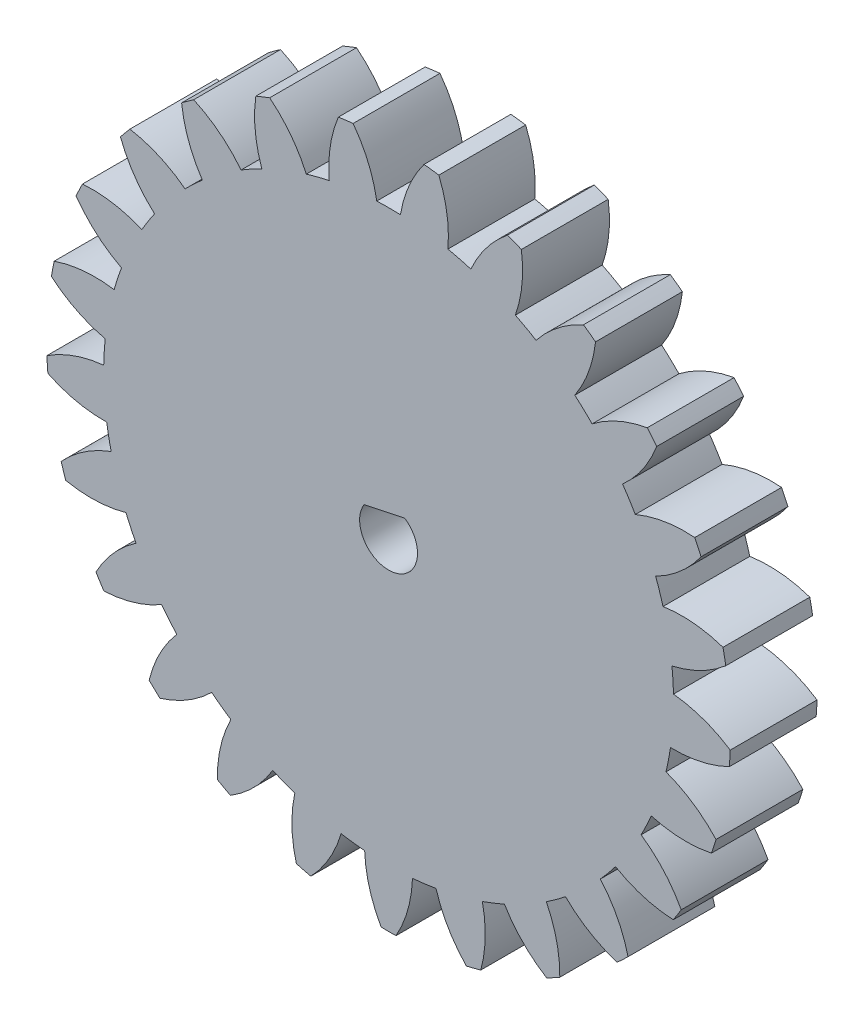
from build123d import *

# Parameters (mm, degrees)
BOSS_EXTRUDE1_DEPTH = 6
CUT_EXTRUDE1_DEPTH  = 6


with BuildPart() as part:
    # Sketch1 → Boss-Extrude1 (new body)
    with BuildSketch(Plane.XY):
        with BuildLine():
            ThreePointArc((-23.297478626, 3.98388923), (-21.550990273, 2.825758414), (-19.579218077, 2.11610853))
            ThreePointArc((-19.579218077, 2.11610853), (-19.647653189, 1.299796091), (-19.682068786, 0.481343326))
            ThreePointArc((-19.682068786, 0.481343326), (-21.727235684, 0.024417829), (-23.605104735, -0.905687747))
            ThreePointArc((-23.605104735, -0.905687747), (-23.578381459, -1.419755495), (-23.540464241, -1.93311898))
            ThreePointArc((-23.540464241, -1.93311898), (-21.560829609, -2.620530995), (-19.474521512, -2.817526118))
            ThreePointArc((-19.474521512, -2.817526118), (-19.337797961, -3.625211721), (-19.167591403, -4.426510099))
            ThreePointArc((-19.167591403, -4.426510099), (-21.034872872, -5.377692766), (-22.622437362, -6.745584408))
            ThreePointArc((-22.622437362, -6.745584408), (-22.468710197, -7.236855963), (-22.304315911, -7.724661561))
            ThreePointArc((-22.304315911, -7.724661561), (-20.215922725, -7.898162151), (-18.146169139, -7.570124585))
            ThreePointArc((-18.146169139, -7.570124585), (-17.812877768, -8.318433495), (-17.448743759, -9.052228961))
            ThreePointArc((-17.448743759, -9.052228961), (-19.020811637, -10.437902494), (-20.218319051, -12.157630537))
            ThreePointArc((-20.218319051, -12.157630537), (-19.94724724, -12.595237503), (-19.666705383, -13.026834594))
            ThreePointArc((-19.666705383, -13.026834594), (-17.600775067, -12.675522078), (-15.677626222, -11.843063629))
            ThreePointArc((-15.677626222, -11.843063629), (-15.168708954, -12.484976846), (-14.633527372, -13.105162332))
            ThreePointArc((-14.633527372, -13.105162332), (-15.811602852, -14.838259766), (-16.543809396, -16.801767375))
            ThreePointArc((-16.543809396, -16.801767375), (-16.172425378, -17.158213294), (-15.793363427, -17.506483047))
            ThreePointArc((-15.793363427, -17.506483047), (-13.879705981, -16.652431682), (-12.22400039, -15.367858777))
            ThreePointArc((-12.22400039, -15.367858777), (-11.571434369, -15.863042531), (-10.898832642, -16.330649503))
            ThreePointArc((-10.898832642, -16.330649503), (-11.60889291, -18.302273952), (-11.829791353, -20.386186721))
            ThreePointArc((-11.829791353, -20.386186721), (-11.381430551, -20.639074787), (-10.927666363, -20.882134132))
            ThreePointArc((-10.927666363, -20.882134132), (-9.286523922, -19.579007107), (-8.002295658, -17.923034185))
            ThreePointArc((-8.002295658, -17.923034185), (-7.247084006, -18.240374261), (-6.479324175, -18.526021252))
            ThreePointArc((-6.479324175, -18.526021252), (-6.676753531, -20.612288301), (-6.372464012, -22.685666328))
            ThreePointArc((-6.372464012, -22.685666328), (-5.875298584, -22.819106653), (-5.375343832, -22.941683276))
            ThreePointArc((-5.375343832, -22.941683276), (-4.109835412, -21.271360855), (-3.277777259, -19.348038785))
            ThreePointArc((-3.277777259, -19.348038785), (-2.467372703, -19.467595539), (-1.65269594, -19.553334298))
            ThreePointArc((-1.65269594, -19.553334298), (-1.325089173, -21.623156117), (-0.514731321, -23.555721434))
            ThreePointArc((-0.514731321, -23.555721434), (0, -23.561329471), (0.514731321, -23.555721434))
            ThreePointArc((0.514731321, -23.555721434), (1.325089173, -21.623156117), (1.65269594, -19.553334298))
            ThreePointArc((1.65269594, -19.553334298), (2.467372703, -19.467595539), (3.277777259, -19.348038785))
            ThreePointArc((3.277777259, -19.348038785), (4.109835412, -21.271360855), (5.375343832, -22.941683276))
            ThreePointArc((5.375343832, -22.941683276), (5.875298584, -22.819106653), (6.372464012, -22.685666328))
            ThreePointArc((6.372464012, -22.685666328), (6.676753531, -20.612288301), (6.479324175, -18.526021252))
            ThreePointArc((6.479324175, -18.526021252), (7.247084006, -18.240374261), (8.002295658, -17.923034185))
            ThreePointArc((8.002295658, -17.923034185), (9.286523922, -19.579007107), (10.927666363, -20.882134132))
            ThreePointArc((10.927666363, -20.882134132), (11.381430551, -20.639074787), (11.829791353, -20.386186721))
            ThreePointArc((11.829791353, -20.386186721), (11.60889291, -18.302273952), (10.898832642, -16.330649503))
            ThreePointArc((10.898832642, -16.330649503), (11.571434369, -15.863042531), (12.22400039, -15.367858777))
            ThreePointArc((12.22400039, -15.367858777), (13.879705981, -16.652431682), (15.793363427, -17.506483047))
            ThreePointArc((15.793363427, -17.506483047), (16.172425378, -17.158213294), (16.543809396, -16.801767375))
            ThreePointArc((16.543809396, -16.801767375), (15.811602852, -14.838259766), (14.633527372, -13.105162332))
            ThreePointArc((14.633527372, -13.105162332), (15.168708954, -12.484976846), (15.677626222, -11.843063629))
            ThreePointArc((15.677626222, -11.843063629), (17.600775067, -12.675522078), (19.666705383, -13.026834594))
            ThreePointArc((19.666705383, -13.026834594), (19.94724724, -12.595237503), (20.218319051, -12.157630537))
            ThreePointArc((20.218319051, -12.157630537), (19.020811637, -10.437902494), (17.448743759, -9.052228961))
            ThreePointArc((17.448743759, -9.052228961), (17.812877768, -8.318433495), (18.146169139, -7.570124585))
            ThreePointArc((18.146169139, -7.570124585), (20.215922725, -7.898162151), (22.304315911, -7.724661561))
            ThreePointArc((22.304315911, -7.724661561), (22.468710197, -7.236855963), (22.622437362, -6.745584408))
            ThreePointArc((22.622437362, -6.745584408), (21.034872872, -5.377692766), (19.167591403, -4.426510099))
            ThreePointArc((19.167591403, -4.426510099), (19.337797961, -3.625211721), (19.474521512, -2.817526118))
            ThreePointArc((19.474521512, -2.817526118), (21.560829609, -2.620530995), (23.540464241, -1.93311898))
            ThreePointArc((23.540464241, -1.93311898), (23.578381459, -1.419755495), (23.605104735, -0.905687747))
            ThreePointArc((23.605104735, -0.905687747), (21.727235684, 0.024417829), (19.682068786, 0.481343326))
            ThreePointArc((19.682068786, 0.481343326), (19.647653189, 1.299796091), (19.579218077, 2.11610853))
            ThreePointArc((19.579218077, 2.11610853), (21.550990273, 2.825758414), (23.297478626, 3.98388923))
            ThreePointArc((23.297478626, 3.98388923), (23.206536298, 4.490554086), (23.104576563, 4.995117258))
            ThreePointArc((23.104576563, 4.995117258), (21.054396371, 5.428994815), (18.959849401, 5.362952832))
            ThreePointArc((18.959849401, 5.362952832), (18.722974108, 6.147133588), (18.453680362, 6.920780951))
            ThreePointArc((18.453680362, 6.920780951), (20.18702296, 8.098495683), (21.590626747, 9.654575682))
            ThreePointArc((21.590626747, 9.654575682), (21.376539115, 10.122706292), (21.152302873, 10.586061329))
            ThreePointArc((21.152302873, 10.586061329), (19.058631901, 10.496448744), (17.046312949, 9.911588942))
            ThreePointArc((17.046312949, 9.911588942), (16.621861705, 10.612224728), (16.168630043, 11.294595904))
            ThreePointArc((16.168630043, 11.294595904), (17.554630751, 12.866375338), (18.527156386, 14.722630289))
            ThreePointArc((18.527156386, 14.722630289), (18.203375361, 15.122812286), (17.870952201, 15.515844888))
            ThreePointArc((17.870952201, 15.515844888), (15.865343497, 14.908372849), (14.061693963, 13.84144412))
            ThreePointArc((14.061693963, 13.84144412), (13.476336601, 14.414511412), (12.867645233, 14.962730512))
            ThreePointArc((12.867645233, 14.962730512), (13.819216531, 16.829813965), (14.29955665, 18.869608544))
            ThreePointArc((14.29955665, 18.869608544), (13.886426585, 19.176697021), (13.466703877, 19.474711502))
            ThreePointArc((13.466703877, 19.474711502), (11.675177211, 18.387549712), (10.19352703, 16.905591112))
            ThreePointArc((10.19352703, 16.905591112), (9.484043705, 17.315081985), (8.75813895, 17.694702387))
            ThreePointArc((8.75813895, 17.694702387), (9.215490113, 19.739774138), (9.17346318, 21.834940549))
            ThreePointArc((9.17346318, 21.834940549), (8.696942557, 22.029640008), (8.216293022, 22.213911023))
            ThreePointArc((8.216293022, 22.213911023), (6.751416603, 20.715369856), (5.684863304, 18.911498294))
            ThreePointArc((5.684863304, 18.911498294), (4.895833464, 19.13168293), (4.098326587, 19.318851687))
            ThreePointArc((4.098326587, 19.318851687), (4.032720558, 21.413412357), (3.47096728, 23.43230359))
            ThreePointArc((3.47096728, 23.43230359), (2.960997643, 23.502380347), (2.449622259, 23.561329471))
            ThreePointArc((2.449622259, 23.561329471), (1.40343966, 21.745567779), (0.818998709, 19.733127139))
            ThreePointArc((0.818998709, 19.733127139), (0, 19.750170529), (-0.818998709, 19.733127139))
            ThreePointArc((-0.818998709, 19.733127139), (-1.40343966, 21.745567779), (-2.449622259, 23.561329471))
            ThreePointArc((-2.449622259, 23.561329471), (-2.960997643, 23.502380347), (-3.47096728, 23.43230359))
            ThreePointArc((-3.47096728, 23.43230359), (-4.032720558, 21.413412357), (-4.098326587, 19.318851687))
            ThreePointArc((-4.098326587, 19.318851687), (-4.895833464, 19.13168293), (-5.684863304, 18.911498294))
            ThreePointArc((-5.684863304, 18.911498294), (-6.751416603, 20.715369856), (-8.216293022, 22.213911023))
            ThreePointArc((-8.216293022, 22.213911023), (-8.696942557, 22.029640008), (-9.17346318, 21.834940549))
            ThreePointArc((-9.17346318, 21.834940549), (-9.215490113, 19.739774138), (-8.75813895, 17.694702387))
            ThreePointArc((-8.75813895, 17.694702387), (-9.484043705, 17.315081985), (-10.19352703, 16.905591112))
            ThreePointArc((-10.19352703, 16.905591112), (-11.675177211, 18.387549712), (-13.466703877, 19.474711502))
            ThreePointArc((-13.466703877, 19.474711502), (-13.886426585, 19.176697021), (-14.29955665, 18.869608544))
            ThreePointArc((-14.29955665, 18.869608544), (-13.819216531, 16.829813965), (-12.867645233, 14.962730512))
            ThreePointArc((-12.867645233, 14.962730512), (-13.476336601, 14.414511412), (-14.061693963, 13.84144412))
            ThreePointArc((-14.061693963, 13.84144412), (-15.865343497, 14.908372849), (-17.870952201, 15.515844888))
            ThreePointArc((-17.870952201, 15.515844888), (-18.203375361, 15.122812286), (-18.527156386, 14.722630289))
            ThreePointArc((-18.527156386, 14.722630289), (-17.554630751, 12.866375338), (-16.168630043, 11.294595904))
            ThreePointArc((-16.168630043, 11.294595904), (-16.621861705, 10.612224728), (-17.046312949, 9.911588942))
            ThreePointArc((-17.046312949, 9.911588942), (-19.058631901, 10.496448744), (-21.152302873, 10.586061329))
            ThreePointArc((-21.152302873, 10.586061329), (-21.376539115, 10.122706292), (-21.590626747, 9.654575682))
            ThreePointArc((-21.590626747, 9.654575682), (-20.18702296, 8.098495683), (-18.453680362, 6.920780951))
            ThreePointArc((-18.453680362, 6.920780951), (-18.722974108, 6.147133588), (-18.959849401, 5.362952832))
            ThreePointArc((-18.959849401, 5.362952832), (-21.054396371, 5.428994815), (-23.104576563, 4.995117258))
            ThreePointArc((-23.104576563, 4.995117258), (-23.206536298, 4.490554086), (-23.297478626, 3.98388923))
        make_face()
    extrude(amount=BOSS_EXTRUDE1_DEPTH)

    # Sketch2 → Cut-Extrude1 (cut)
    with BuildSketch(Plane.XY.offset(6)):
        with BuildLine():
            Line((-1.68792147, 1.136480442), (1.106353759, 1.729798183))
            ThreePointArc((1.106353759, 1.729798183), (0.415405508, -1.892713448), (-1.68792147, 1.136480442))
        make_face()
    extrude(amount=-CUT_EXTRUDE1_DEPTH, mode=Mode.SUBTRACT)


solid = part.part
